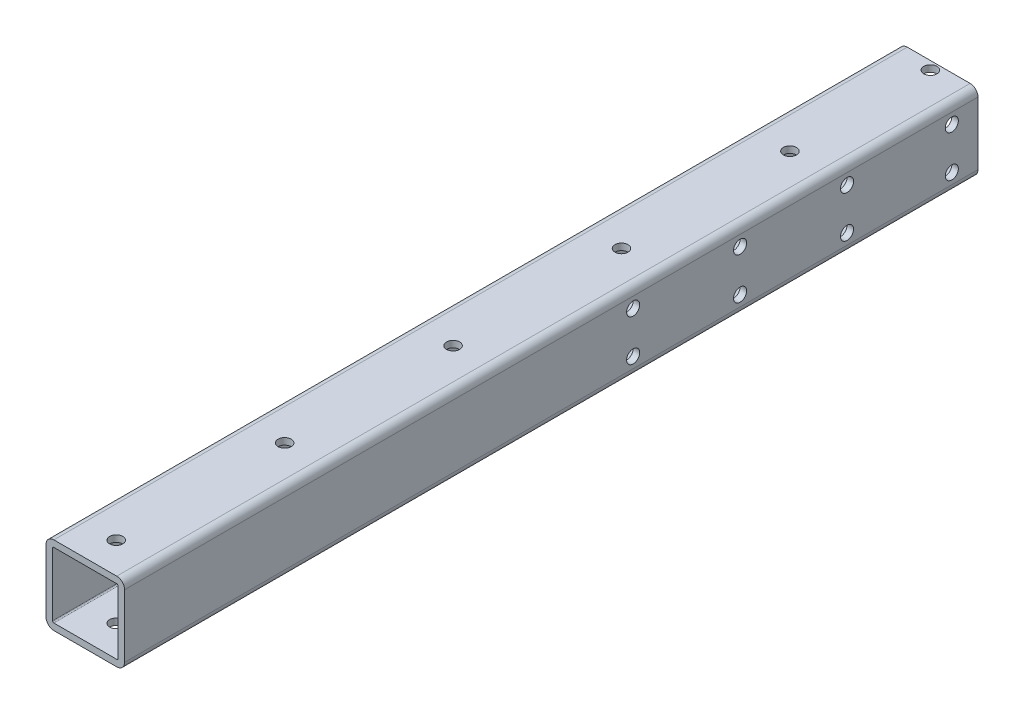
from build123d import *

# Parameters (mm, degrees)
SKETCH1_W               = 38.1
SKETCH1_H               = 38.1
SKETCH1_W_2             = 31.75
SKETCH1_H_2             = 31.75
BOSS_EXTRUDE1_DEPTH     = 206.9
FILLET1_R               = 3.81
FILLET2_R               = 0.635
SKETCH2_R               = 3.175
CUT_EXTRUDE1_DEPTH      = 1
CUT_EXTRUDE1_DEPTH_BACK = 39.1
SKETCH3_R               = 3.175
CUT_EXTRUDE2_DEPTH      = 39.1


with BuildPart() as part:
    # Sketch1 → Boss-Extrude1 (new body, symmetric)
    with BuildSketch(Plane.XY):
        Rectangle(SKETCH1_W, SKETCH1_H)
        Rectangle(SKETCH1_W_2, SKETCH1_H_2, mode=Mode.SUBTRACT)
    extrude(amount=BOSS_EXTRUDE1_DEPTH, both=True)

    # Fillet1
    fillet1_edges = [part.edges().sort_by_distance(p)[0] for p in [
        (19.05, -19.05, 0),
        (-19.05, -19.05, 0),
        (-19.05, 19.05, 0),
        (19.05, 19.05, 0),
    ]]
    fillet(fillet1_edges, radius=FILLET1_R)

    # Fillet2
    fillet2_edges = [part.edges().sort_by_distance(p)[0] for p in [
        (15.875, 15.875, 0),
        (-15.875, 15.875, 0),
        (-15.875, -15.875, 0),
        (15.875, -15.875, 0),
    ]]
    fillet(fillet2_edges, radius=FILLET2_R)

    # Sketch2 → Cut-Extrude1 (cut, two sides)
    with BuildSketch(Plane(origin=(0, 19.05, 0), x_dir=(1, 0, 0), z_dir=(0, 1, 0))) as cut_extrude1_sk:
        with Locations((0, 202.85)):
            Circle(SKETCH2_R)
        with Locations((0, 134.75)):
            Circle(SKETCH2_R)
        with Locations((0, 53.0875)):
            Circle(SKETCH2_R)
        with Locations((0, -28.575)):
            Circle(SKETCH2_R)
        with Locations((0, -110.2375)):
            Circle(SKETCH2_R)
        with Locations((0, -191.9)):
            Circle(SKETCH2_R)
    extrude(amount=CUT_EXTRUDE1_DEPTH, mode=Mode.SUBTRACT)
    extrude(cut_extrude1_sk.sketch, amount=-CUT_EXTRUDE1_DEPTH_BACK, mode=Mode.SUBTRACT)

    # Sketch3 → Cut-Extrude2 (cut, through all)
    with BuildSketch(Plane(origin=(19.05, 0, 0), x_dir=(0, 0, -1), z_dir=(1, 0, 0))):
        with Locations((194.2, 10.05)):
            Circle(SKETCH3_R)
        with Locations((194.2, -10.05)):
            Circle(SKETCH3_R)
        with Locations((143.4, 10.05)):
            Circle(SKETCH3_R)
        with Locations((39.7, 10.05)):
            Circle(SKETCH3_R)
        with Locations((91.55, 10.05)):
            Circle(SKETCH3_R)
        with Locations((143.4, -10.05)):
            Circle(SKETCH3_R)
        with Locations((91.55, -10.05)):
            Circle(SKETCH3_R)
        with Locations((39.7, -10.05)):
            Circle(SKETCH3_R)
    extrude(amount=-CUT_EXTRUDE2_DEPTH, mode=Mode.SUBTRACT)


solid = part.part
